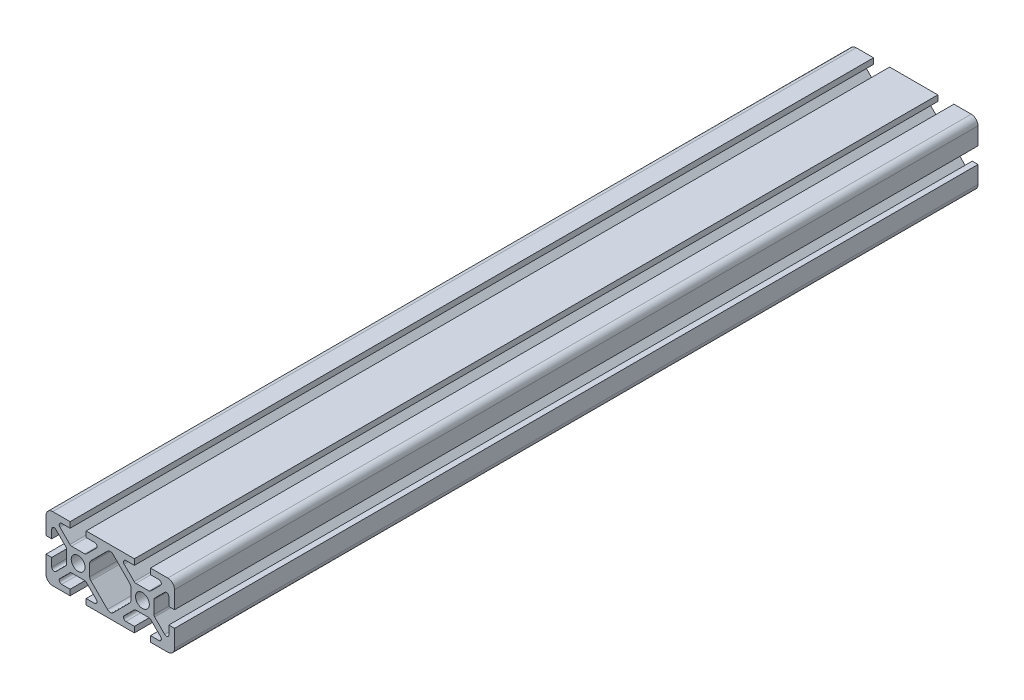
from build123d import *

# Parameters (mm, degrees)
BOSS_EXTRUDE1_DEPTH = 125
BOSS_EXTRUDE2_DEPTH = 125
FILLET1_R           = 0.75
FILLET2_R           = 1.25


with BuildPart() as part:
    # Sketch3 → Boss-Extrude1 (new body, symmetric)
    with BuildSketch(Plane.XY):
        with BuildLine():
            Line((12.5, -10), (17.9, -10))
            ThreePointArc((17.9, -10), (19.38492424, -9.38492424), (20, -7.9))
            Line((20, -7.9), (20, -2.5))
            Line((20, -2.5), (18.213351365, -2.5))
            Line((18.213351365, -2.5), (18.213351365, -6.95))
            Line((18.213351365, -6.95), (13.6, -2.336648635))
            Line((13.6, -2.336648635), (13.6, 0))
            Line((13.6, 0), (12.15, 0))
            ThreePointArc((12.15, 0), (11.52027958, -1.52027958), (10, -2.15))
            Line((10, -2.15), (10, -3.6))
            Line((10, -3.6), (12.336648635, -3.6))
            Line((12.336648635, -3.6), (16.95, -8.213351365))
            Line((16.95, -8.213351365), (12.5, -8.213351365))
            Line((12.5, -8.213351365), (12.5, -10))
        make_face()
    extrude(amount=BOSS_EXTRUDE1_DEPTH, both=True)

    # Sketch4 → Boss-Extrude2 (add, symmetric)
    with BuildSketch(Plane.XY):
        with BuildLine():
            Line((10, -3.6), (7.663351365, -3.6))
            Line((7.663351365, -3.6), (3.05, -8.213351365))
            Line((3.05, -8.213351365), (7.5, -8.213351365))
            Line((7.5, -8.213351365), (7.5, -10))
            Line((7.5, -10), (0, -10))
            Line((0, -10), (0, -8.736648635))
            Line((0, -8.736648635), (6.4, -2.336648635))
            Line((6.4, -2.336648635), (6.4, 0))
            Line((6.4, 0), (7.85, 0))
            ThreePointArc((7.85, 0), (8.47972042, -1.52027958), (10, -2.15))
            Line((10, -2.15), (10, -3.6))
        make_face()
    extrude(amount=BOSS_EXTRUDE2_DEPTH, both=True)

    # Mirror1: part across plane


with BuildPart() as part_1:
    add(part.part)
    add(part.part.mirror(Plane(origin=(0, 0, 0), x_dir=(0, 0, 1), z_dir=(1, 0, 0))))

    # Mirror2: part across plane


with BuildPart() as part_2:
    add(part_1.part)
    add(part_1.part.mirror(Plane.ZX))

    # Fillet1
    fillet1_edges = [part_2.edges().sort_by_distance(p)[0] for p in [
        (18.213351365, 6.95, 0),
        (13.6, 2.336648635, 0),
        (12.336648635, 3.6, 0),
        (16.95, 8.213351365, 0),
        (3.05, 8.213351365, 0),
        (7.663351365, 3.6, 0),
        (-18.213351365, 6.95, 0),
        (-13.6, 2.336648635, 0),
        (-7.663351365, 3.6, 0),
        (-12.336648635, 3.6, 0),
        (-16.95, 8.213351365, 0),
        (-3.05, 8.213351365, 0),
        (16.95, -8.213351365, 0),
        (12.336648635, -3.6, 0),
        (13.6, -2.336648635, 0),
        (18.213351365, -6.95, 0),
        (3.05, -8.213351365, 0),
        (7.663351365, -3.6, 0),
        (-18.213351365, -6.95, 0),
        (-13.6, -2.336648635, 0),
        (-12.336648635, -3.6, 0),
        (-16.95, -8.213351365, 0),
        (-3.05, -8.213351365, 0),
        (-7.663351365, -3.6, 0),
    ]]
    fillet(fillet1_edges, radius=FILLET1_R)

    # Fillet2
    fillet2_edges = [part_2.edges().sort_by_distance(p)[0] for p in [
        (6.4, 2.336648635, 0),
        (0, 8.736648635, 0),
        (-6.4, 2.336648635, 0),
        (6.4, -2.336648635, 0),
        (-6.4, -2.336648635, 0),
        (0, -8.736648635, 0),
    ]]
    fillet(fillet2_edges, radius=FILLET2_R)


solid = part_2.part
